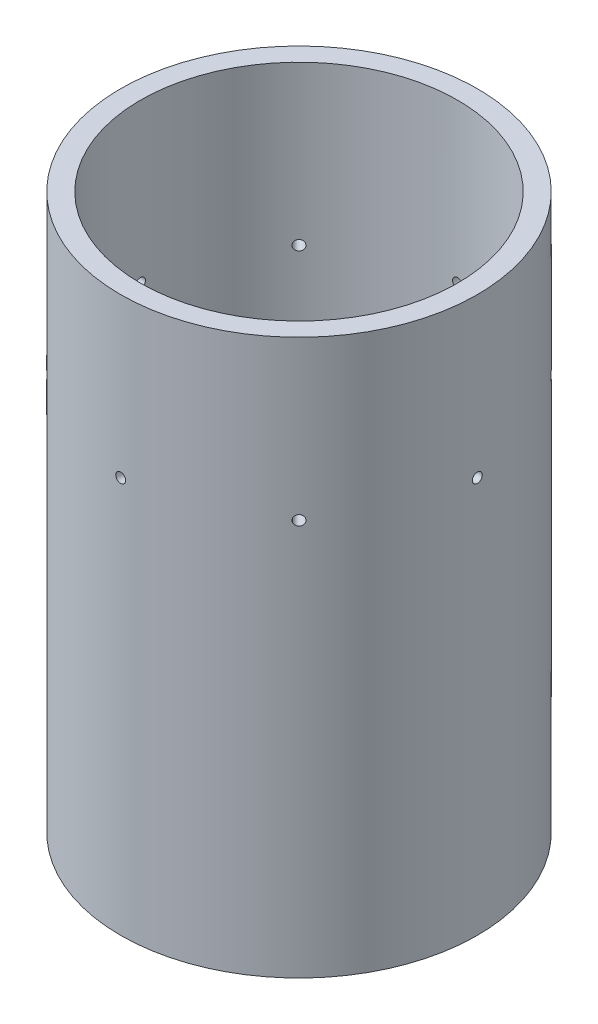
from build123d import *

# Parameters (mm, degrees)
SKETCH1_R           = 57.15
SKETCH1_R_2         = 50.8
BOSS_EXTRUDE1_DEPTH = 177.8
SKETCH3_R           = 1.5875
CUT_EXTRUDE1_DEPTH  = 6.35
CIRPATTERN1_COUNT   = 8


with BuildPart() as part:
    # Sketch1 → Boss-Extrude1 (new body)
    with BuildSketch(Plane(origin=(0, 0, 0), x_dir=(1, 0, 0), z_dir=(0, 1, 0))):
        Circle(SKETCH1_R)
        Circle(SKETCH1_R_2, mode=Mode.SUBTRACT)
    extrude(amount=BOSS_EXTRUDE1_DEPTH)

    # Sketch3 → Cut-Extrude1 (cut, symmetric)
    with BuildSketch(Plane.XY.offset(53.975)):
        with Locations((0, 127)):
            Circle(SKETCH3_R)
    cut_extrude1 = extrude(amount=CUT_EXTRUDE1_DEPTH, both=True, mode=Mode.SUBTRACT)

    # CirPattern1: Cut-Extrude1 ×8 about axis
    cirpattern1_axis = Axis((0, 177.8, 0), (0, 1, 0))
    for i in range(1, CIRPATTERN1_COUNT):
        add(cut_extrude1.rotate(cirpattern1_axis, i * 360 / CIRPATTERN1_COUNT), mode=Mode.SUBTRACT)


solid = part.part
